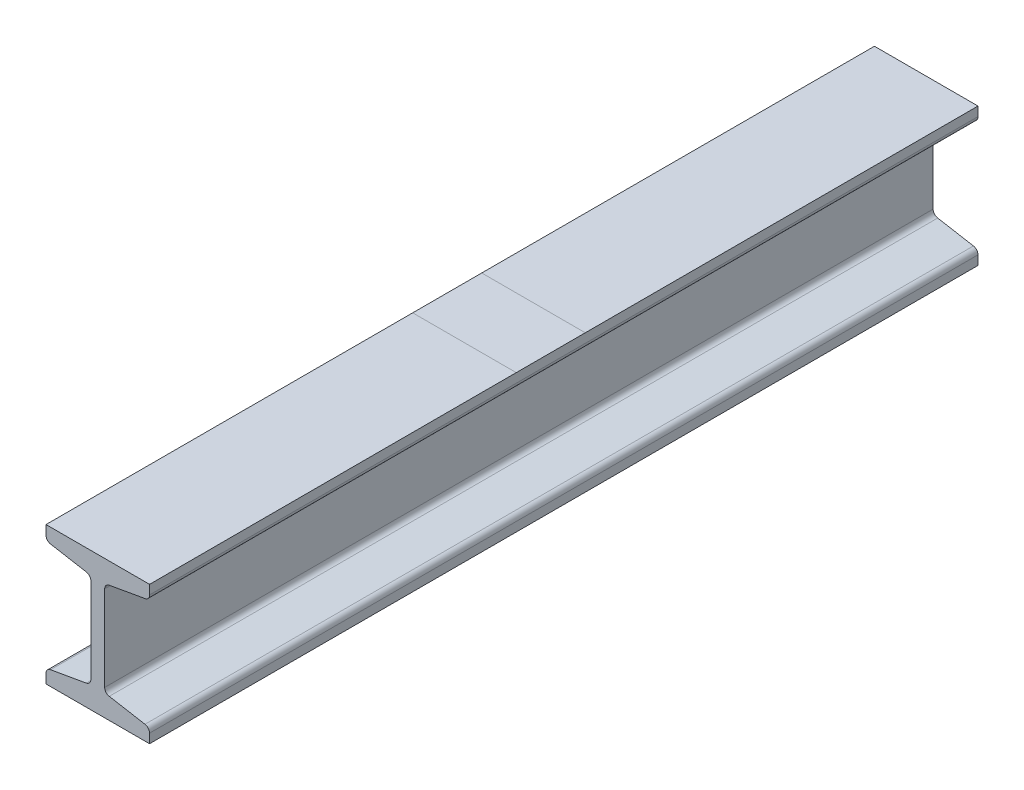
from build123d import *

# Parameters (mm, degrees)
BOSS_EXTRUDE1_DEPTH = 600
FILLET1_R           = 4


with BuildPart() as part:
    # Sketch2 → Boss-Extrude1 (new body)
    with BuildSketch(Plane.XY):
        Polygon((37.5, 50), (37.5, 40), (5, 34.269373127), (5, -34.269373127), (37.5, -40), (37.5, -50), (-37.5, -50), (-37.5, -40), (-5, -34.269373127), (-5, 34.269373127), (-37.5, 40), (-37.5, 50), align=None)
    extrude(amount=BOSS_EXTRUDE1_DEPTH)

    # Fillet1
    fillet1_edges = [part.edges().sort_by_distance(p)[0] for p in [
        (37.5, 40, 300),
        (5, 34.269373127, 300),
        (5, -34.269373127, 300),
        (37.5, -40, 300),
        (-37.5, -40, 300),
        (-5, -34.269373127, 300),
        (-5, 34.269373127, 300),
        (-37.5, 40, 300),
    ]]
    fillet(fillet1_edges, radius=FILLET1_R)


solid = part.part
